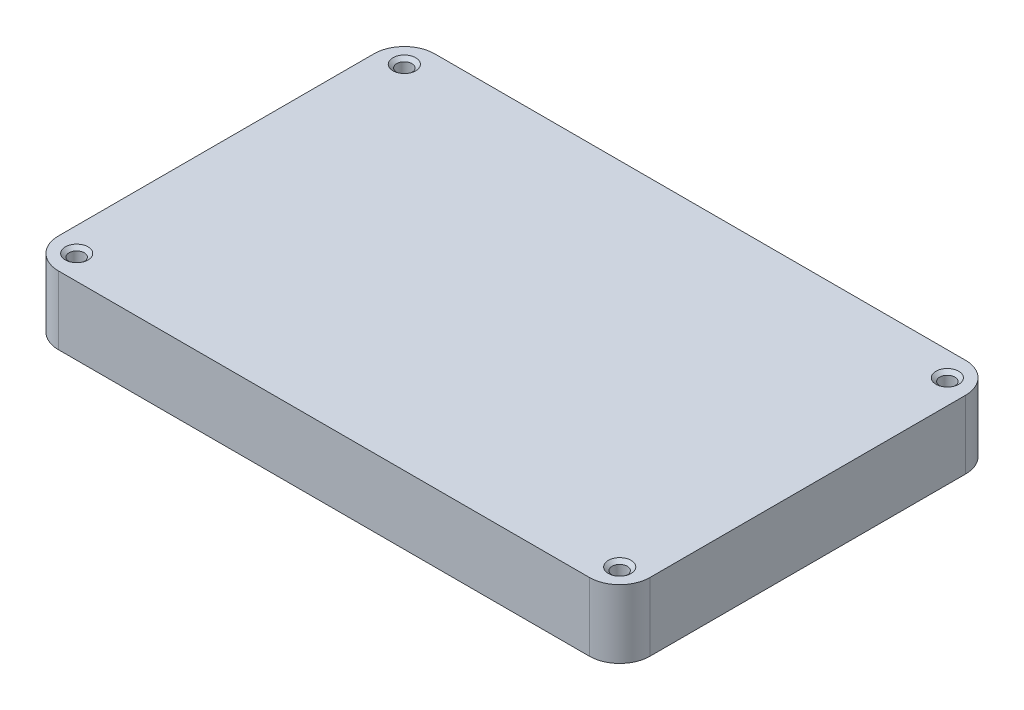
from build123d import *

# Parameters (mm, degrees)
BOSS_EXTRUDE1_DEPTH                    = 14.2875
F_97_0_0059_DIAMETER_HOLE1_D           = 3.175
F_97_0_0059_DIAMETER_HOLE1_CSINK_D     = 4.7625
F_97_0_0059_DIAMETER_HOLE1_CSINK_ANGLE = 100
CUT_EXTRUDE1_DEPTH                     = 12.065


with BuildPart() as part:
    # Sketch1 → Boss-Extrude1 (new body)
    with BuildSketch(Plane(origin=(0, 0, 0), x_dir=(1, 0, 0), z_dir=(0, 1, 0))):
        with BuildLine():
            Line((6.35, 0), (117.475, 0))
            ThreePointArc((117.475, 0), (121.965128061, 1.859871939), (123.825, 6.35))
            Line((123.825, 6.35), (123.825, 72.39))
            ThreePointArc((123.825, 72.39), (121.965128061, 76.880128061), (117.475, 78.74))
            Line((117.475, 78.74), (6.35, 78.74))
            ThreePointArc((6.35, 78.74), (1.859871939, 76.880128061), (0, 72.39))
            Line((0, 72.39), (0, 6.35))
            ThreePointArc((0, 6.35), (1.859871939, 1.859871939), (6.35, 0))
        make_face()
    extrude(amount=BOSS_EXTRUDE1_DEPTH)

    # #97 (0.0059) Diameter Hole1 (through all)
    with Locations(Plane(origin=(0, 14.2875, 0), x_dir=(1, 0, 0), z_dir=(0, 1, 0))):
        with Locations((5.08, 5.08), (5.08, 73.66), (118.745, 73.66), (118.745, 5.08)):
            CounterSinkHole(F_97_0_0059_DIAMETER_HOLE1_D / 2, F_97_0_0059_DIAMETER_HOLE1_CSINK_D / 2, counter_sink_angle=F_97_0_0059_DIAMETER_HOLE1_CSINK_ANGLE)

    # Sketch5 → Cut-Extrude1 (cut)
    with BuildSketch(Plane(origin=(0, 0, 0), x_dir=(-1, 0, 0), z_dir=(0, -1, 0))):
        with BuildLine():
            Line((-111.125, 73.18375), (-111.125, 62.865))
            ThreePointArc((-111.125, 62.865), (-112.984871939, 58.374871939), (-117.475, 56.515))
            Line((-117.475, 56.515), (-118.26875, 56.515))
            Line((-118.26875, 56.515), (-118.26875, 12.7))
            Line((-118.26875, 12.7), (-117.475, 12.7))
            ThreePointArc((-117.475, 12.7), (-112.984871939, 10.840128061), (-111.125, 6.35))
            Line((-111.125, 6.35), (-111.125, 5.55625))
            Line((-111.125, 5.55625), (-12.7, 5.55625))
            Line((-12.7, 5.55625), (-12.7, 15.875))
            ThreePointArc((-12.7, 15.875), (-10.840128061, 20.365128061), (-6.35, 22.225))
            Line((-6.35, 22.225), (-5.55625, 22.225))
            Line((-5.55625, 22.225), (-5.55625, 56.515))
            Line((-5.55625, 56.515), (-10.16, 56.515))
            ThreePointArc((-10.16, 56.515), (-11.956051224, 57.258948776), (-12.7, 59.055))
            Line((-12.7, 59.055), (-12.7, 73.18375))
            Line((-12.7, 73.18375), (-111.125, 73.18375))
        make_face()
    extrude(amount=-CUT_EXTRUDE1_DEPTH, mode=Mode.SUBTRACT)


solid = part.part
